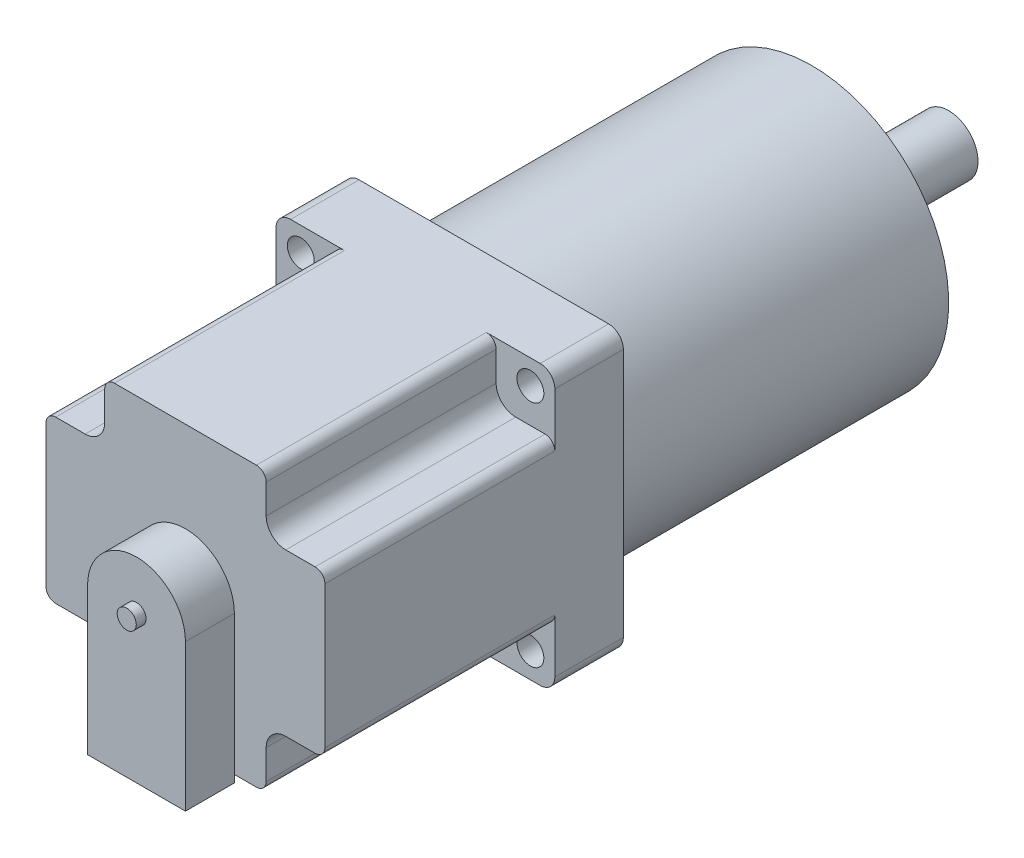
from build123d import *

# Parameters (mm, degrees)
BOSS_EXTRUDE1_DEPTH            = 56
SKETCH2_W                      = 19.654725719
SKETCH2_H                      = 18.883952161
CUT_EXTRUDE1_DEPTH             = 47
FILLET1_R                      = 2
FILLET2_R                      = 4
M5_CLEARANCE_HOLE2_D           = 5.5
M5_CLEARANCE_HOLE2_CSINK_D     = 5.55
M5_CLEARANCE_HOLE2_CSINK_ANGLE = 90
SKETCH6_R                      = 1.95
BOSS_EXTRUDE2_DEPTH            = 12
BOSS_EXTRUDE3_DEPTH            = 5
SKETCH8_R                      = 28
BOSS_EXTRUDE4_DEPTH            = 67
SKETCH9_R                      = 16
BOSS_EXTRUDE5_DEPTH            = 2
CIRPATTERN1_COUNT              = 4
SKETCH14_R                     = 6
BOSS_EXTRUDE6_DEPTH            = 26
SKETCH17_R                     = 1.907386748
BOSS_EXTRUDE7_DEPTH            = 10


with BuildPart() as part:
    # Sketch1 → Boss-Extrude1 (new body)
    with BuildSketch(Plane.XY):
        with BuildLine():
            Line((-3, 0), (-54, 0))
            ThreePointArc((-54, 0), (-56.121320344, -0.878679656), (-57, -3))
            Line((-57, -3), (-57, -54))
            ThreePointArc((-57, -54), (-56.121320344, -56.121320344), (-54, -57))
            Line((-54, -57), (-3, -57))
            ThreePointArc((-3, -57), (-0.878679656, -56.121320344), (0, -54))
            Line((0, -54), (0, -3))
            ThreePointArc((0, -3), (-0.878679656, -0.878679656), (-3, 0))
        make_face()
    extrude(amount=BOSS_EXTRUDE1_DEPTH)

    # Sketch2 → Cut-Extrude1 (cut)
    with BuildSketch(Plane.XY.offset(56)):
        with Locations((-54.827362859, -2.558023919)):
            Rectangle(SKETCH2_W, SKETCH2_H)
        with Locations((-2.17263714, -2.558023919)):
            Rectangle(SKETCH2_W, SKETCH2_H)
        with Locations((-2.17263714, -54.44197608)):
            Rectangle(SKETCH2_W, SKETCH2_H)
        with Locations((-54.827362859, -54.44197608)):
            Rectangle(SKETCH2_W, SKETCH2_H)
    extrude(amount=-CUT_EXTRUDE1_DEPTH, mode=Mode.SUBTRACT)

    # Fillet1
    fillet1_edges = [part.edges().sort_by_distance(p)[0] for p in [
        (-57, -45, 32.5),
        (-45, -57, 32.5),
        (-12, -57, 32.5),
        (0, -45, 32.5),
        (0, -12, 32.5),
        (-12, 0, 32.5),
        (-45, 0, 32.5),
        (-57, -12, 32.5),
    ]]
    fillet(fillet1_edges, radius=FILLET1_R)

    # Fillet2
    fillet2_edges = [part.edges().sort_by_distance(p)[0] for p in [
        (-45, -45, 32.5),
        (-12, -45, 32.5),
        (-12, -12, 32.5),
        (-45, -12, 32.5),
    ]]
    fillet(fillet2_edges, radius=FILLET2_R)

    # M5 Clearance Hole2 (through all)
    with Locations(Plane(origin=(0, 0, 0), x_dir=(-1, 0, 0), z_dir=(0, 0, -1))):
        with Locations((51.921563773, -4.957706516), (4.997949753, -4.957706516), (4.997949753, -51.800834063), (51.921563773, -52.283752904)):
            CounterSinkHole(M5_CLEARANCE_HOLE2_D / 2, M5_CLEARANCE_HOLE2_CSINK_D / 2, counter_sink_angle=M5_CLEARANCE_HOLE2_CSINK_ANGLE)

    # Sketch6 → Boss-Extrude2 (add)
    with BuildSketch(Plane.XY.offset(56)):
        with Locations((-28.5, -28.5)):
            Circle(SKETCH6_R)
    extrude(amount=BOSS_EXTRUDE2_DEPTH)

    # Sketch7 → Boss-Extrude3 (add)
    with BuildSketch(Plane(origin=(0, 0, 0), x_dir=(-1, 0, 0), z_dir=(0, 0, -1))):
        with BuildLine():
            Line((57, -54), (57, -3))
            ThreePointArc((57, -3), (56.121320344, -0.878679656), (54, 0))
            Line((54, 0), (3, 0))
            ThreePointArc((3, 0), (0.878679656, -0.878679656), (0, -3))
            Line((0, -3), (0, -54))
            ThreePointArc((0, -54), (0.878679656, -56.121320344), (3, -57))
            Line((3, -57), (54, -57))
            ThreePointArc((54, -57), (56.121320344, -56.121320344), (57, -54))
        make_face()
    extrude(amount=BOSS_EXTRUDE3_DEPTH)

    # Sketch8 → Boss-Extrude4 (add)
    with BuildSketch(Plane(origin=(0, 0, -5), x_dir=(-1, 0, 0), z_dir=(0, 0, -1))):
        with Locations((28.5, -28.5)):
            Circle(SKETCH8_R)
    extrude(amount=BOSS_EXTRUDE4_DEPTH)

    # Sketch9 → Boss-Extrude5 (add)
    with BuildSketch(Plane(origin=(0, 0, -72), x_dir=(-1, 0, 0), z_dir=(0, 0, -1))):
        with Locations((28.5, -28.5)):
            Circle(SKETCH9_R)
    extrude(amount=BOSS_EXTRUDE5_DEPTH)

    # Sketch13 → M5 Clearance Hole1 (revolve, cut)
    with BuildSketch(Plane(origin=(-44.409902577, -12.590097423, -72), x_dir=(0, 1, 0), z_dir=(1, 0, 0))):
        Polygon((0, 0), (0, 21.652366702), (2.75, 20), (2.75, 0.025), (2.775, 0), align=None)
    m5_clearance_hole1 = revolve(axis=Axis((-44.409902577, -12.590097423, -78.35), (0, 0, 1)), mode=Mode.SUBTRACT)

    # CirPattern1: M5 Clearance Hole1 ×4 about axis
    cirpattern1_axis = Axis((-28.5, -28.5, 0), (0, 0, 1))
    for i in range(1, CIRPATTERN1_COUNT):
        add(m5_clearance_hole1.rotate(cirpattern1_axis, i * 360 / CIRPATTERN1_COUNT), mode=Mode.SUBTRACT)

    # Sketch14 → Boss-Extrude6 (add)
    with BuildSketch(Plane(origin=(0, 0, -74), x_dir=(-1, 0, 0), z_dir=(0, 0, -1))):
        with Locations((28.5, -28.5)):
            Circle(SKETCH14_R)
    extrude(amount=BOSS_EXTRUDE6_DEPTH)

    # Sketch17 → Boss-Extrude7 (add)
    with BuildSketch(Plane.XY.offset(56)):
        with BuildLine():
            Line((-18.5, -28.5), (-18.5, -58.5))
            Line((-18.5, -58.5), (-38.5, -58.5))
            Line((-38.5, -58.5), (-38.5, -28.5))
            ThreePointArc((-38.5, -28.5), (-28.5, -18.5), (-18.5, -28.5))
        make_face()
        with Locations((-28.5, -28.5)):
            Circle(SKETCH17_R, mode=Mode.SUBTRACT)
    extrude(amount=BOSS_EXTRUDE7_DEPTH)


solid = part.part
